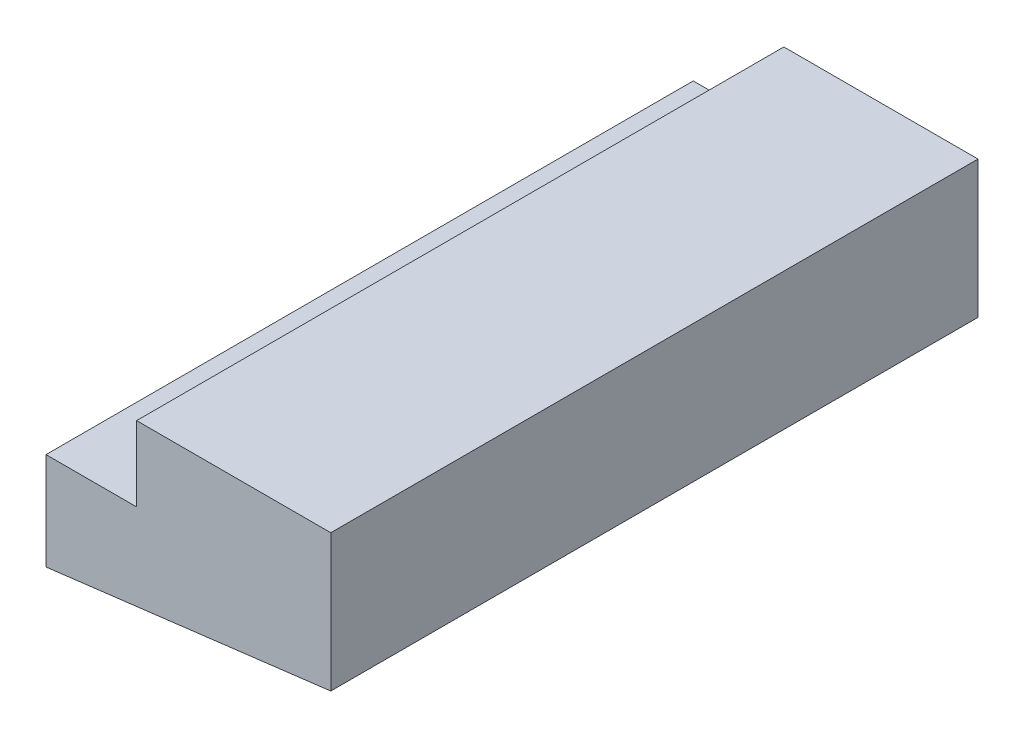
from build123d import *

# Parameters (mm, degrees)
BOSS_EXTRUDE1_DEPTH = 250


with BuildPart() as part:
    # Sketch2 → Boss-Extrude1 (new body)
    with BuildSketch(Plane.XY):
        Polygon((105, 0), (180, 0), (180, -52.96839306), (70, -66.474694759), (70, -28.872571319), (105, -28.872571319), align=None)
    extrude(amount=BOSS_EXTRUDE1_DEPTH)


solid = part.part
